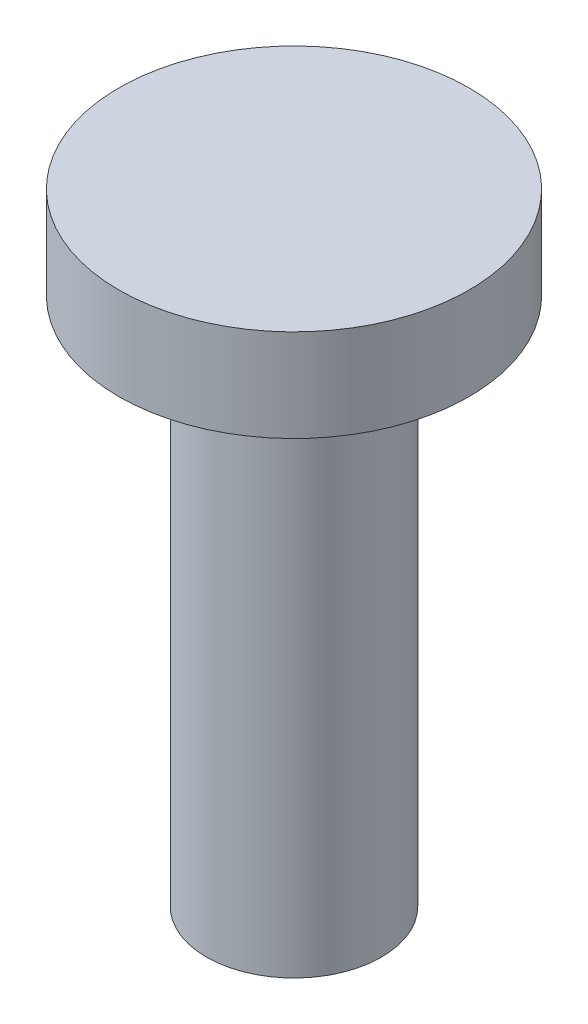
from build123d import *

# Parameters (mm, degrees)
SKETCH1_R           = 3.175
BOSS_EXTRUDE1_DEPTH = 20
SKETCH2_R           = 1.675
CUT_EXTRUDE1_DEPTH  = 12
SKETCH4_R           = 6.35
BOSS_EXTRUDE2_DEPTH = 2.54
SKETCH6_R           = 6.35
BOSS_EXTRUDE3_DEPTH = 3.35


with BuildPart() as part:
    # Sketch1 → Boss-Extrude1 (new body)
    with BuildSketch(Plane(origin=(0, 0, 0), x_dir=(1, 0, 0), z_dir=(0, 1, 0))):
        Circle(SKETCH1_R)
    extrude(amount=BOSS_EXTRUDE1_DEPTH)

    # Sketch2 → Cut-Extrude1 (cut)
    with BuildSketch(Plane.XZ):
        Circle(SKETCH2_R)
    extrude(amount=-CUT_EXTRUDE1_DEPTH, mode=Mode.SUBTRACT)

    # Sketch4 → Boss-Extrude2 (add)
    with BuildSketch(Plane(origin=(0, 20, 0), x_dir=(1, 0, 0), z_dir=(0, 1, 0))):
        Circle(SKETCH4_R)
    extrude(amount=BOSS_EXTRUDE2_DEPTH)

    # Sketch6 → Boss-Extrude3 (add)
    with BuildSketch(Plane(origin=(0, 22.54, 0), x_dir=(1, 0, 0), z_dir=(0, 1, 0))):
        Circle(SKETCH6_R)
    extrude(amount=-BOSS_EXTRUDE3_DEPTH)


solid = part.part
